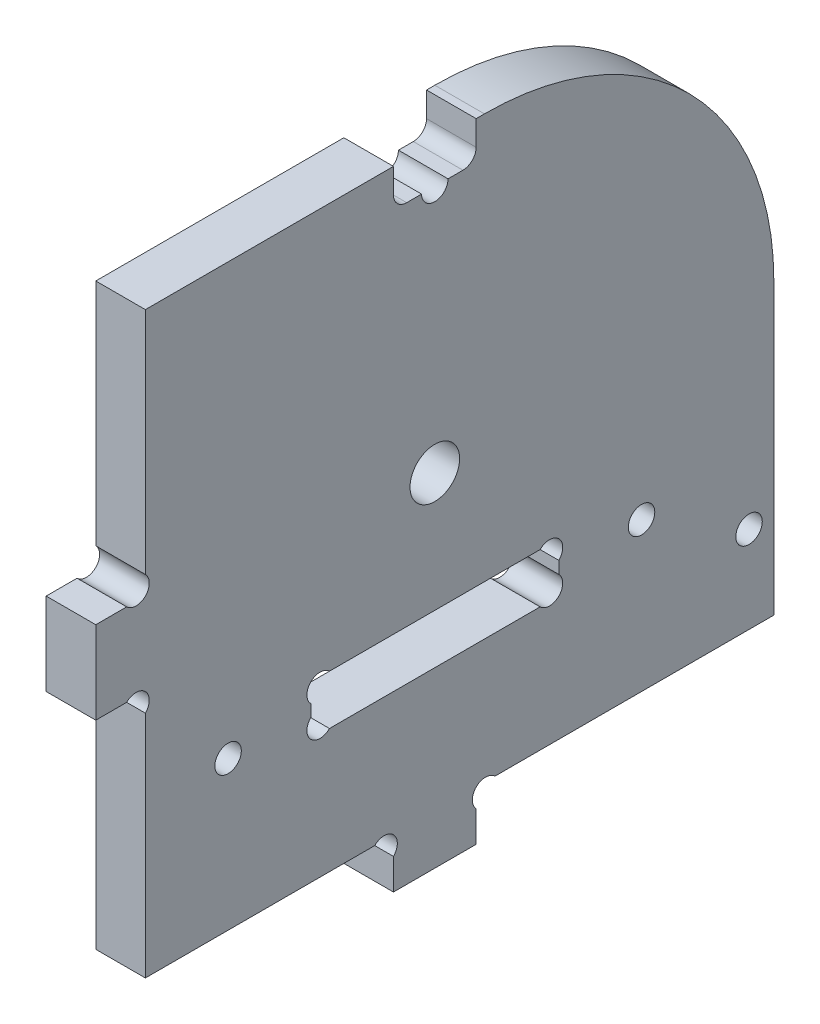
from build123d import *

# Parameters (mm, degrees)
ESQUISSE1_R        = 3
ESQUISSE1_R_2      = 1.6
BOSS_EXTRU_1_DEPTH = 6


with BuildPart() as part:
    # Esquisse1 → Boss.-Extru.1 (new body)
    with BuildSketch(Plane(origin=(0, 0, 0), x_dir=(0, 0, -1), z_dir=(1, 0, 0))):
        with BuildLine():
            Line((46, 3.7372583), (46, 0))
            Line((46, 0), (36, 0))
            Line((36, 0), (36, 3.7372583))
            ThreePointArc((36, 3.7372583), (36, 6), (33.7372583, 6))
            Line((33.7372583, 6), (6, 6))
            Line((6, 6), (6, 33.7372583))
            ThreePointArc((6, 33.7372583), (6, 36), (3.7372583, 36))
            Line((3.7372583, 36), (0, 36))
            Line((0, 36), (0, 46))
            Line((0, 46), (3.7372583, 46))
            ThreePointArc((3.7372583, 46), (6, 46), (6, 48.2627417))
            Line((6, 48.2627417), (6, 76))
            Line((6, 76), (36, 76))
            Line((36, 76), (36, 73))
            ThreePointArc((36, 73), (36.46862915, 71.86862915), (37.6, 71.4))
            Line((37.6, 71.4), (39.4, 71.4))
            ThreePointArc((39.4, 71.4), (41, 69.8), (42.6, 71.4))
            Line((42.6, 71.4), (44.4, 71.4))
            ThreePointArc((44.4, 71.4), (45.53137085, 71.86862915), (46, 73))
            Line((46, 73), (46, 76))
            Line((46, 76), (47, 76))
            ThreePointArc((47, 76), (71.748737342, 65.748737342), (82, 41))
            Line((82, 41), (82, 6))
            Line((82, 6), (48.2627417, 6))
            ThreePointArc((48.2627417, 6), (46, 6), (46, 3.7372583))
        make_face()
        with Locations((41, 41.4)):
            Circle(ESQUISSE1_R, mode=Mode.SUBTRACT)
        with Locations((79, 16.5)):
            Circle(ESQUISSE1_R_2, mode=Mode.SUBTRACT)
        with Locations((66, 24)):
            Circle(ESQUISSE1_R_2, mode=Mode.SUBTRACT)
        with Locations(Location((16, 24, 0), (0, 0, 180))):  # turned: the seam where the file's is
            Circle(ESQUISSE1_R_2, mode=Mode.SUBTRACT)
        with BuildLine():
            Line((56, 24.7372583), (56, 23.2627417))
            ThreePointArc((56, 23.2627417), (56, 21), (53.7372583, 21))
            Line((53.7372583, 21), (28.2627417, 21))
            ThreePointArc((28.2627417, 21), (26, 21), (26, 23.2627417))
            Line((26, 23.2627417), (26, 24.7372583))
            ThreePointArc((26, 24.7372583), (26, 27), (28.2627417, 27))
            Line((28.2627417, 27), (53.7372583, 27))
            ThreePointArc((53.7372583, 27), (56, 27), (56, 24.7372583))
        make_face(mode=Mode.SUBTRACT)
    extrude(amount=BOSS_EXTRU_1_DEPTH)


solid = part.part
